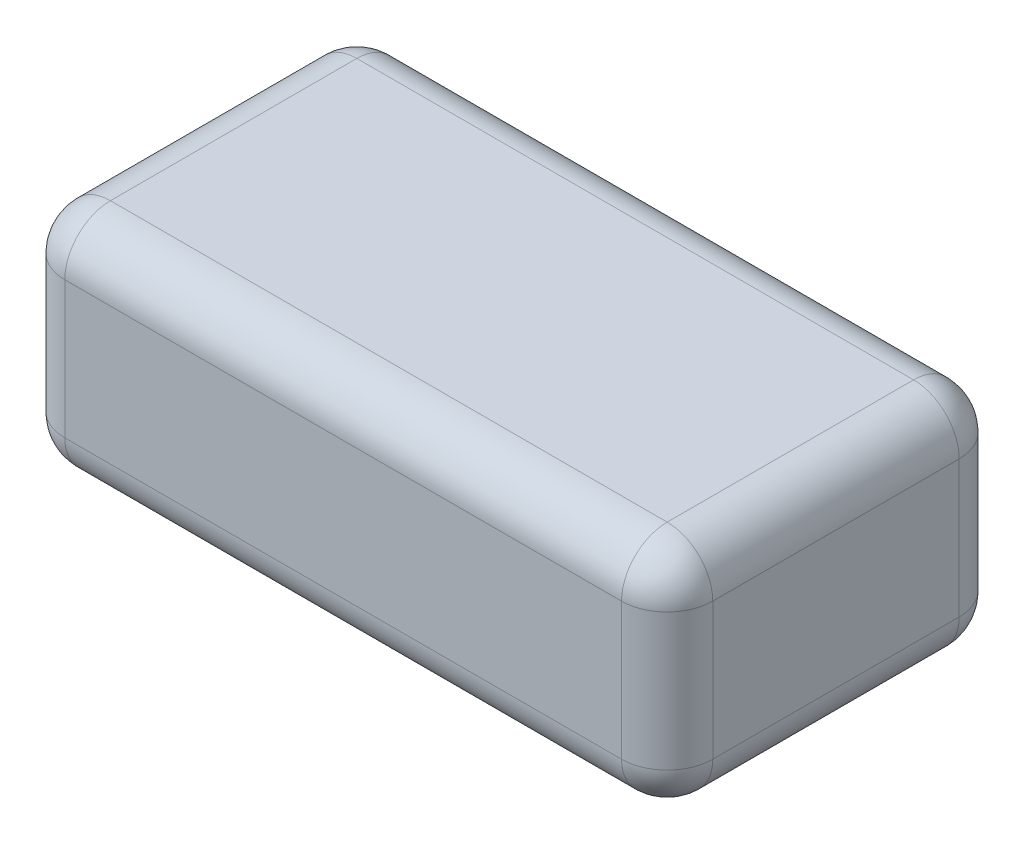
from build123d import *

# Parameters (mm, degrees)
CROQUIS1_W              = 71
CROQUIS1_H              = 37
SALIENTE_EXTRUIR1_DEPTH = 25
REDONDEO3_R             = 5


with BuildPart() as part:
    # Croquis1 → Saliente-Extruir1 (new body)
    with BuildSketch(Plane(origin=(0, 0, 0), x_dir=(1, 0, 0), z_dir=(0, 1, 0))):
        Rectangle(CROQUIS1_W, CROQUIS1_H)
    extrude(amount=SALIENTE_EXTRUIR1_DEPTH)

    # Redondeo3
    redondeo3_edges = [part.edges().sort_by_distance(p)[0] for p in [
        (-35.5, 25, 0),
        (0, 25, 18.5),
        (35.5, 25, 0),
        (0, 0, 18.5),
        (-35.5, 0, 0),
        (0, 0, -18.5),
        (35.5, 0, 0),
        (0, 25, -18.5),
        (35.5, 12.5, 18.5),
        (-35.5, 12.5, 18.5),
        (-35.5, 12.5, -18.5),
        (35.5, 12.5, -18.5),
    ]]
    fillet(redondeo3_edges, radius=REDONDEO3_R)


solid = part.part
